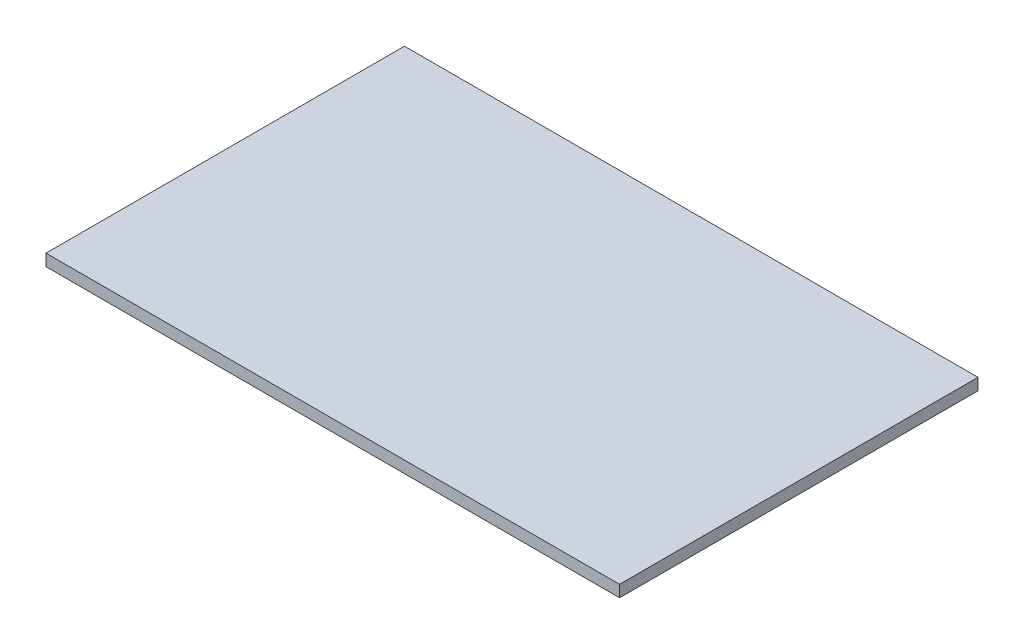
from build123d import *

# Parameters (mm, degrees)
SKETCH_1_W      = 880
SKETCH_1_H      = 550
EXTRUDE_1_DEPTH = 18


with BuildPart() as part:
    # Эскиз1 → Бобышка-Вытянуть1 (new body)
    with BuildSketch(Plane(origin=(0, 0, 0), x_dir=(1, 0, 0), z_dir=(0, 1, 0))):
        Rectangle(SKETCH_1_W, SKETCH_1_H)
    extrude(amount=EXTRUDE_1_DEPTH)


solid = part.part
